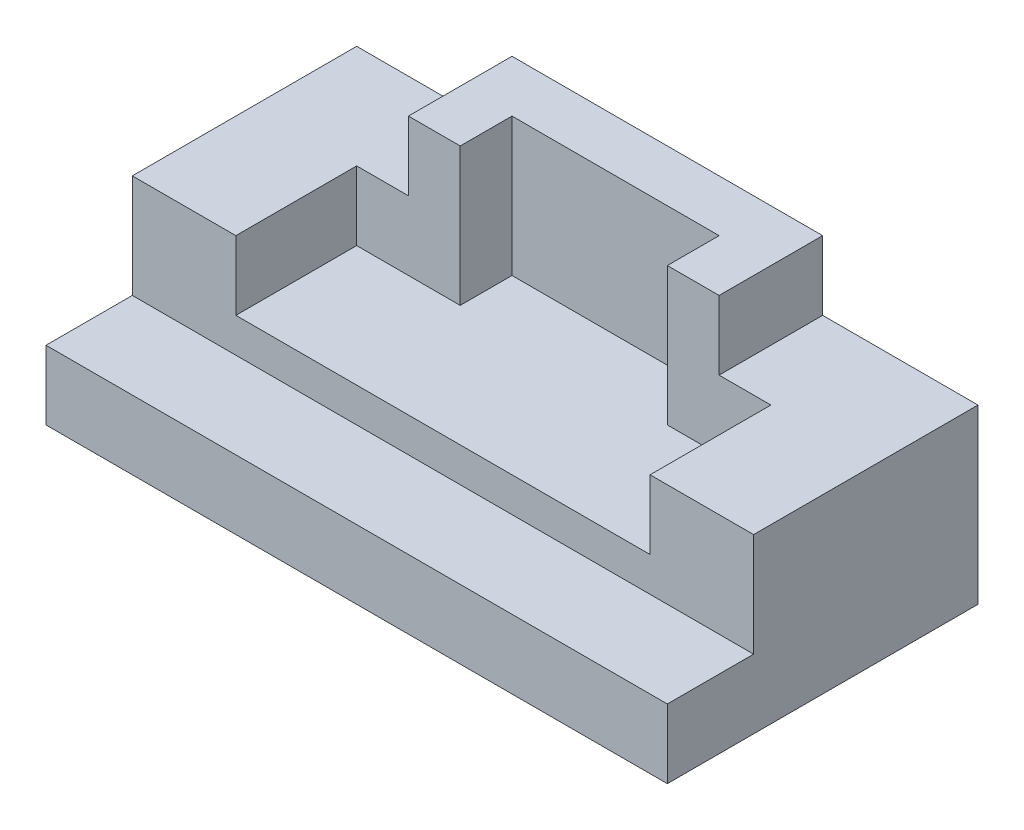
from build123d import *

# Parameters (mm, degrees)
BOSS_EXTRUDE1_DEPTH = 57.15
BOSS_EXTRUDE2_DEPTH = 12.7
CUT_EXTRUDE1_DEPTH  = 25.4


with BuildPart() as part:
    # Sketch1 → Boss-Extrude1 (new body, symmetric)
    with BuildSketch(Plane(origin=(0, 0, 0), x_dir=(0, 0, -1), z_dir=(1, 0, 0))):
        Polygon((-28.575, 0), (28.575, 0), (28.575, 31.75), (-12.7, 31.75), (-12.7, 12.7), (-28.575, 12.7), align=None)
    extrude(amount=BOSS_EXTRUDE1_DEPTH, both=True)

    # Sketch2 → Boss-Extrude2 (add)
    with BuildSketch(Plane(origin=(0, 31.75, 0), x_dir=(1, 0, 0), z_dir=(0, 1, 0))):
        Polygon((-28.575, 28.575), (28.575, 28.575), (28.575, 9.525), (19.05, 9.525), (19.05, 19.05), (-19.05, 19.05), (-19.05, 9.525), (-28.575, 9.525), align=None)
    extrude(amount=BOSS_EXTRUDE2_DEPTH)

    # Sketch3 → Cut-Extrude1 (cut)
    with BuildSketch(Plane(origin=(0, 44.45, 0), x_dir=(1, 0, 0), z_dir=(0, 1, 0))):
        Polygon((-38.1, 9.525), (-19.05, 9.525), (-19.05, 19.05), (19.05, 19.05), (19.05, 9.525), (38.1, 9.525), (38.1, -12.7), (-38.1, -12.7), align=None)
    extrude(amount=-CUT_EXTRUDE1_DEPTH, mode=Mode.SUBTRACT)


solid = part.part
